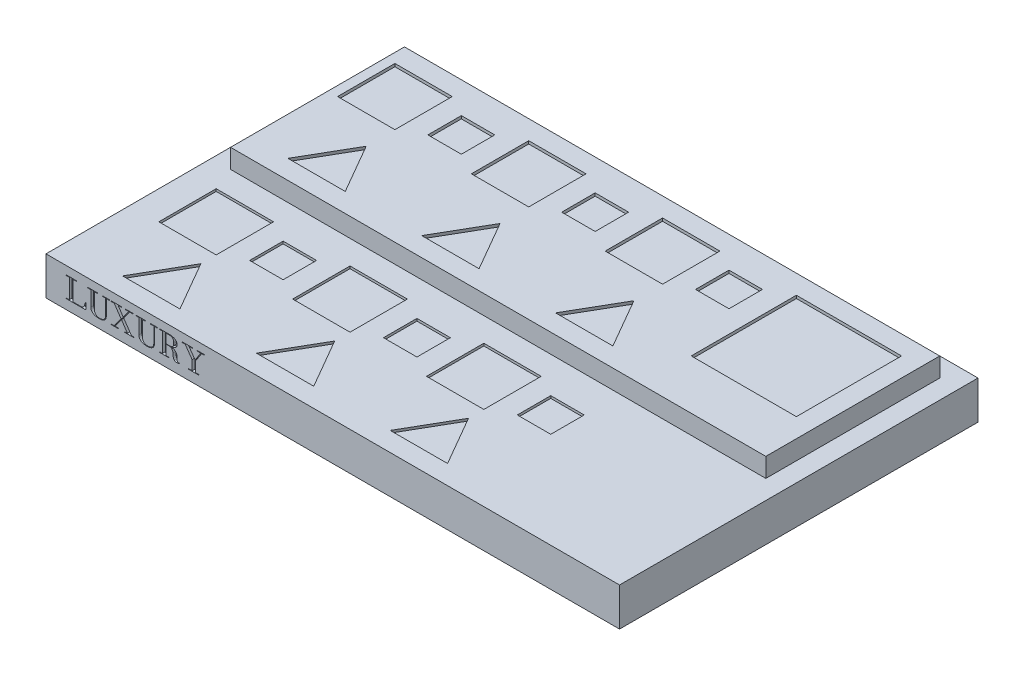
from build123d import *

# Parameters (mm, degrees)
SKETCH1_W           = 600
SKETCH1_H           = 375
BOSS_EXTRUDE3_DEPTH = 40
CUT_EXTRUDE1_DEPTH  = 3
SKETCH5_R           = 25
SKETCH5_W           = 60
SKETCH5_H           = 60
CUT_EXTRUDE2_DEPTH  = 3
SKETCH6_W           = 560
SKETCH6_H           = 181.961524227
BOSS_EXTRUDE4_DEPTH = 20
SKETCH8_W           = 60
SKETCH8_H           = 60
SKETCH8_W_2         = 35
SKETCH8_H_2         = 35
SKETCH8_W_3         = 110
SKETCH8_H_3         = 110
CUT_EXTRUDE12_DEPTH = 3
SKETCH8_7_W         = 60
SKETCH8_7_H         = 60
SKETCH8_7_W_2       = 35
SKETCH8_7_H_2       = 35
CUT_EXTRUDE13_DEPTH = 22.5


with BuildPart() as part:
    # Sketch1 → Boss-Extrude3 (new body)
    with BuildSketch(Plane(origin=(0, 0, 0), x_dir=(1, 0, 0), z_dir=(0, 1, 0))):
        Rectangle(SKETCH1_W, SKETCH1_H)
    extrude(amount=-BOSS_EXTRUDE3_DEPTH)

    # Sketch2 → Cut-Extrude1 (cut)
    with BuildSketch(Plane.XY.offset(187.5)):
        with BuildLine():
            add(Edge.make_bspline(
                [(-258.895558648, -23.936742187), (-258.997269322, -24.328875191), (-259.191725751, -25.078578054), (-259.466634354, -25.9856335), (-259.720538833, -26.645863024), (-259.929426881, -27.099135568), (-260.174917938, -27.515424324), (-260.443382228, -27.901972822), (-260.751834109, -28.246508697), (-261.09308975, -28.555337155), (-261.480890253, -28.810047091), (-261.903130637, -29.031704786), (-262.375316644, -29.200067568), (-262.902279881, -29.313090604), (-263.482805759, -29.39096417), (-263.890288122, -29.397666543), (-264.102662001, -29.401159722)],
                knots=[0, 0, 0, 0, 0.001215404, 0.002323681, 0.002840622, 0.003336647, 0.00381889, 0.004288788, 0.00474608, 0.005203372, 0.005665307, 0.006134016, 0.006631253, 0.007163568, 0.007748504, 0.008385201, 0.008385201, 0.008385201, 0.008385201], degree=3))
            Line((-264.102662001, -29.401159722), (-271.901620931, -29.401159722))
            Line((-271.901620931, -29.401159722), (-271.901620931, -9.040590278))
            Line((-271.901620931, -9.040590278), (-268.289865506, -9.040590278))
            Line((-268.289865506, -9.040590278), (-268.289865506, -8.44175))
            Line((-268.289865506, -8.44175), (-278.85846072, -8.44175))
            Line((-278.85846072, -8.44175), (-278.85846072, -9.040590278))
            Line((-278.85846072, -9.040590278), (-275.588231391, -9.040590278))
            Line((-275.588231391, -9.040590278), (-275.588231391, -29.401159722))
            Line((-275.588231391, -29.401159722), (-278.85846072, -29.401159722))
            Line((-278.85846072, -29.401159722), (-278.85846072, -30))
            Line((-278.85846072, -30), (-259.274512261, -30))
            add(Edge.make_bspline(
                [(-259.274512261, -30), (-259.188418744, -29.996502143), (-259.025444389, -29.989880726), (-258.798907857, -29.938643412), (-258.601632119, -29.855451762), (-258.447477975, -29.724175967), (-258.318622939, -29.566398032), (-258.237314891, -29.368031161), (-258.184675279, -29.138805425), (-258.178414328, -28.974213972), (-258.175078939, -28.886531359)],
                knots=[0, 0, 0, 0, 0.000257994, 0.00048838, 0.000693593, 0.000893072, 0.001089622, 0.00129911, 0.001529496, 0.001792156, 0.001792156, 0.001792156, 0.001792156], degree=3))
            Line((-258.175078939, -28.886531359), (-258.175078939, -24.034989421))
            add(Edge.make_bspline(
                [(-258.175078939, -24.034989421), (-258.177842651, -23.920401065), (-258.182623748, -23.722168357), (-258.229247011, -23.47393322), (-258.325636232, -23.292791061), (-258.432069631, -23.268929615), (-258.479177517, -23.258368435)],
                knots=[0, 0, 0, 0, 0.000342038, 0.000591711, 0.000766887, 0.000905987, 0.000905987, 0.000905987, 0.000905987], degree=3))
            add(Edge.make_bspline(
                [(-258.479177517, -23.258368435), (-258.523973094, -23.26803895), (-258.624594211, -23.28976114), (-258.731891004, -23.446992928), (-258.825800689, -23.660647313), (-258.870391303, -23.837132407), (-258.895558648, -23.936742187)],
                knots=[0, 0, 0, 0, 0.000133151, 0.000299087, 0.000535661, 0.000842197, 0.000842197, 0.000842197, 0.000842197], degree=3))
        make_face()
        with BuildLine():
            Line((-246.179559625, -8.44175), (-256.406628743, -8.44175))
            Line((-256.406628743, -8.44175), (-256.406628743, -9.040590278))
            Line((-256.406628743, -9.040590278), (-253.136399414, -9.040590278))
            Line((-253.136399414, -9.040590278), (-253.136399414, -24.853716363))
            add(Edge.make_bspline(
                [(-253.136399414, -24.853716363), (-253.129091047, -25.127464043), (-253.114938624, -25.657567788), (-252.958944178, -26.414012673), (-252.724115678, -27.107572296), (-252.376163673, -27.72398883), (-251.948943331, -28.269132845), (-251.474815745, -28.768124964), (-250.935649017, -29.203146874), (-250.346164703, -29.587332901), (-249.708489747, -29.911400279), (-249.036208214, -30.189605845), (-248.327052165, -30.414199964), (-247.587754635, -30.583579351), (-246.832406052, -30.707637561), (-246.076557359, -30.794545846), (-245.325933191, -30.854918852), (-244.827605857, -30.861990832), (-244.579533257, -30.865511339)],
                knots=[0, 0, 0, 0, 0.000820063, 0.001588025, 0.002307137, 0.003008747, 0.003699336, 0.004380944, 0.005069248, 0.005772571, 0.006488174, 0.007211897, 0.007953175, 0.008716922, 0.009485284, 0.010248386, 0.010999038, 0.011743146, 0.011743146, 0.011743146, 0.011743146], degree=3))
            add(Edge.make_bspline(
                [(-244.579533257, -30.865511339), (-244.286204943, -30.86127932), (-243.715819197, -30.853050033), (-242.886020591, -30.782033346), (-242.105950809, -30.6661183), (-241.376490544, -30.504556763), (-240.695059396, -30.293231248), (-240.065763069, -30.032630555), (-239.484028494, -29.726540631), (-238.953680878, -29.37655212), (-238.47592973, -28.978014296), (-238.063995768, -28.526866401), (-237.711135186, -28.03053949), (-237.43257444, -27.483314439), (-237.209864747, -26.892060914), (-237.052638716, -26.25466638), (-236.957991457, -25.569230774), (-236.945888478, -25.097308668), (-236.939641276, -24.853716363)],
                knots=[0, 0, 0, 0, 0.000879858, 0.00171091, 0.002496289, 0.003244269, 0.003950093, 0.004633866, 0.005284724, 0.005919235, 0.006536825, 0.0071461, 0.007747075, 0.008358073, 0.00898285, 0.0096387, 0.010323497, 0.011054068, 0.011054068, 0.011054068, 0.011054068], degree=3))
            Line((-236.939641276, -24.853716363), (-236.939641276, -9.040590278))
            Line((-236.939641276, -9.040590278), (-233.669411947, -9.040590278))
            Line((-233.669411947, -9.040590278), (-233.669411947, -8.44175))
            Line((-233.669411947, -8.44175), (-240.818067763, -8.44175))
            Line((-240.818067763, -8.44175), (-240.818067763, -9.040590278))
            Line((-240.818067763, -9.040590278), (-237.547838433, -9.040590278))
            Line((-237.547838433, -9.040590278), (-237.547838433, -24.853716363))
            add(Edge.make_bspline(
                [(-237.547838433, -24.853716363), (-237.55260588, -25.063025506), (-237.56193744, -25.472716696), (-237.653384597, -26.070468151), (-237.801594332, -26.636272823), (-238.014995859, -27.16422664), (-238.27113127, -27.65795862), (-238.576931246, -28.110490803), (-238.931676118, -28.5202205), (-239.32793145, -28.889910044), (-239.768686468, -29.212852709), (-240.240601997, -29.501694813), (-240.754972662, -29.736694882), (-241.29617451, -29.940588118), (-241.867478876, -30.091376299), (-242.459533566, -30.205850096), (-243.074733858, -30.271087827), (-243.492428818, -30.280567881), (-243.704665039, -30.28538482)],
                knots=[0, 0, 0, 0, 0.000627539, 0.001228313, 0.001809345, 0.002378386, 0.002932934, 0.003475331, 0.00401272, 0.004555621, 0.005097391, 0.005649408, 0.006212417, 0.006791202, 0.007382484, 0.007982565, 0.008598931, 0.009235629, 0.009235629, 0.009235629, 0.009235629], degree=3))
            add(Edge.make_bspline(
                [(-243.704665039, -30.28538482), (-243.921616383, -30.280836566), (-244.344064065, -30.271980206), (-244.958637606, -30.204998245), (-245.538599215, -30.099886928), (-246.082722005, -29.943542197), (-246.595668615, -29.749739912), (-247.070561413, -29.503060407), (-247.512306409, -29.218153132), (-247.916569085, -28.889763553), (-248.279205688, -28.518937858), (-248.592645576, -28.106706744), (-248.857207567, -27.654967942), (-249.076874757, -27.169476723), (-249.247685368, -26.64403873), (-249.359289103, -26.079986375), (-249.439112527, -25.479764546), (-249.4461672, -25.066090108), (-249.449788954, -24.853716363)],
                knots=[0, 0, 0, 0, 0.000650724, 0.001267089, 0.001852511, 0.002416744, 0.002963241, 0.003494712, 0.004018969, 0.004537749, 0.005053863, 0.005571312, 0.006087236, 0.006621173, 0.007167109, 0.007740576, 0.008344077, 0.008980774, 0.008980774, 0.008980774, 0.008980774], degree=3))
            Line((-249.449788954, -24.853716363), (-249.449788954, -9.040590278))
            Line((-249.449788954, -9.040590278), (-246.179559625, -9.040590278))
            Line((-246.179559625, -9.040590278), (-246.179559625, -8.44175))
        make_face()
        Polygon((-221.014232639, -9.040590278), (-221.014232639, -8.44175), (-231.92435395, -8.44175), (-231.92435395, -9.040590278), (-228.65412462, -9.040590278), (-221.43061377, -19.665326769), (-228.696230577, -29.401159722), (-232.003887424, -29.401159722), (-232.003887424, -30), (-224.055218424, -30), (-224.055218424, -29.401159722), (-227.858789876, -29.401159722), (-221.014232639, -20.123813856), (-214.815300076, -29.401159722), (-217.893713379, -29.401159722), (-217.893713379, -30), (-207.704071777, -30), (-207.704071777, -29.401159722), (-210.632775011, -29.401159722), (-218.73115408, -17.471138563), (-212.494794, -9.040590278), (-209.070176161, -9.040590278), (-209.070176161, -8.44175), (-217.056272678, -8.44175), (-217.056272678, -9.040590278), (-213.369662218, -9.040590278), (-219.147535211, -16.993937717), (-224.471599555, -9.040590278), align=None)
        with BuildLine():
            Line((-195.876976291, -8.44175), (-206.10404541, -8.44175))
            Line((-206.10404541, -8.44175), (-206.10404541, -9.040590278))
            Line((-206.10404541, -9.040590278), (-202.833816081, -9.040590278))
            Line((-202.833816081, -9.040590278), (-202.833816081, -24.853716363))
            add(Edge.make_bspline(
                [(-202.833816081, -24.853716363), (-202.826507713, -25.127464043), (-202.812355291, -25.657567788), (-202.656360845, -26.414012673), (-202.421532345, -27.107572296), (-202.07358034, -27.72398883), (-201.646359998, -28.269132845), (-201.172232411, -28.768124964), (-200.633065683, -29.203146874), (-200.04358137, -29.587332901), (-199.405906413, -29.911400279), (-198.733624881, -30.189605845), (-198.024468832, -30.414199964), (-197.285171302, -30.583579351), (-196.529822719, -30.707637561), (-195.773974025, -30.794545846), (-195.023349857, -30.854918852), (-194.525022524, -30.861990832), (-194.276949924, -30.865511339)],
                knots=[0, 0, 0, 0, 0.000820063, 0.001588025, 0.002307137, 0.003008747, 0.003699336, 0.004380944, 0.005069248, 0.005772571, 0.006488174, 0.007211897, 0.007953175, 0.008716922, 0.009485284, 0.010248386, 0.010999038, 0.011743146, 0.011743146, 0.011743146, 0.011743146], degree=3))
            add(Edge.make_bspline(
                [(-194.276949924, -30.865511339), (-193.98362161, -30.86127932), (-193.413235863, -30.853050033), (-192.583437257, -30.782033346), (-191.803367475, -30.6661183), (-191.073907211, -30.504556763), (-190.392476063, -30.293231248), (-189.763179736, -30.032630555), (-189.181445161, -29.726540631), (-188.651097544, -29.37655212), (-188.173346397, -28.978014296), (-187.761412434, -28.526866401), (-187.408551853, -28.03053949), (-187.129991106, -27.483314439), (-186.907281413, -26.892060914), (-186.750055383, -26.25466638), (-186.655408124, -25.569230774), (-186.643305144, -25.097308668), (-186.637057943, -24.853716363)],
                knots=[0, 0, 0, 0, 0.000879858, 0.00171091, 0.002496289, 0.003244269, 0.003950093, 0.004633866, 0.005284724, 0.005919235, 0.006536825, 0.0071461, 0.007747075, 0.008358073, 0.00898285, 0.0096387, 0.010323497, 0.011054068, 0.011054068, 0.011054068, 0.011054068], degree=3))
            Line((-186.637057943, -24.853716363), (-186.637057943, -9.040590278))
            Line((-186.637057943, -9.040590278), (-183.366828613, -9.040590278))
            Line((-183.366828613, -9.040590278), (-183.366828613, -8.44175))
            Line((-183.366828613, -8.44175), (-190.515484429, -8.44175))
            Line((-190.515484429, -8.44175), (-190.515484429, -9.040590278))
            Line((-190.515484429, -9.040590278), (-187.2452551, -9.040590278))
            Line((-187.2452551, -9.040590278), (-187.2452551, -24.853716363))
            add(Edge.make_bspline(
                [(-187.2452551, -24.853716363), (-187.250022546, -25.063025506), (-187.259354106, -25.472716696), (-187.350801264, -26.070468151), (-187.499010999, -26.636272823), (-187.712412526, -27.16422664), (-187.968547937, -27.65795862), (-188.274347913, -28.110490803), (-188.629092785, -28.5202205), (-189.025348116, -28.889910044), (-189.466103135, -29.212852709), (-189.938018664, -29.501694813), (-190.452389329, -29.736694882), (-190.993591176, -29.940588118), (-191.564895543, -30.091376299), (-192.156950232, -30.205850096), (-192.772150525, -30.271087827), (-193.189845485, -30.280567881), (-193.402081706, -30.28538482)],
                knots=[0, 0, 0, 0, 0.000627539, 0.001228313, 0.001809345, 0.002378386, 0.002932934, 0.003475331, 0.00401272, 0.004555621, 0.005097391, 0.005649408, 0.006212417, 0.006791202, 0.007382484, 0.007982565, 0.008598931, 0.009235629, 0.009235629, 0.009235629, 0.009235629], degree=3))
            add(Edge.make_bspline(
                [(-193.402081706, -30.28538482), (-193.61903305, -30.280836566), (-194.041480732, -30.271980206), (-194.656054273, -30.204998245), (-195.236015881, -30.099886928), (-195.780138672, -29.943542197), (-196.293085282, -29.749739912), (-196.76797808, -29.503060407), (-197.209723076, -29.218153132), (-197.613985751, -28.889763553), (-197.976622355, -28.518937858), (-198.290062242, -28.106706744), (-198.554624234, -27.654967942), (-198.774291424, -27.169476723), (-198.945102035, -26.64403873), (-199.05670577, -26.079986375), (-199.136529194, -25.479764546), (-199.143583866, -25.066090108), (-199.147205621, -24.853716363)],
                knots=[0, 0, 0, 0, 0.000650724, 0.001267089, 0.001852511, 0.002416744, 0.002963241, 0.003494712, 0.004018969, 0.004537749, 0.005053863, 0.005571312, 0.006087236, 0.006621173, 0.007167109, 0.007740576, 0.008344077, 0.008980774, 0.008980774, 0.008980774, 0.008980774], degree=3))
            Line((-199.147205621, -24.853716363), (-199.147205621, -9.040590278))
            Line((-199.147205621, -9.040590278), (-195.876976291, -9.040590278))
            Line((-195.876976291, -9.040590278), (-195.876976291, -8.44175))
        make_face()
        with BuildLine():
            add(Edge.make_bspline(
                [(-162.608591797, -28.601146539), (-162.646287126, -28.472422793), (-162.732284525, -28.178754908), (-162.787105054, -27.674183296), (-162.833778123, -27.087711291), (-162.858245031, -26.442940738), (-162.875665445, -25.767547008), (-162.891488385, -25.078061812), (-162.92191675, -24.395074879), (-162.994310596, -23.948766735), (-163.029651367, -23.730890842)],
                knots=[0, 0, 0, 0, 0.00040172, 0.000916476, 0.001517141, 0.002168049, 0.002851358, 0.00354402, 0.004237708, 0.004899339, 0.004899339, 0.004899339, 0.004899339], degree=3))
            add(Edge.make_bspline(
                [(-163.029651367, -23.730890842), (-163.071838114, -23.525894791), (-163.153115994, -23.130945055), (-163.319915401, -22.570007176), (-163.530595792, -22.066781915), (-163.779995461, -21.61702983), (-164.067251218, -21.219330003), (-164.365972671, -20.847039837), (-164.714546004, -20.532284404), (-165.080013048, -20.243215636), (-165.475070443, -19.989625271), (-165.901276138, -19.770448222), (-166.352858679, -19.571491447), (-167.009519404, -19.358235974), (-167.877814558, -19.107239815), (-168.592997663, -18.941467548), (-168.961912869, -18.855956706)],
                knots=[0, 0, 0, 0, 0.000627713, 0.001209366, 0.001752428, 0.002261368, 0.002748128, 0.003223145, 0.003689889, 0.004153149, 0.004620337, 0.005095354, 0.005589877, 0.006098817, 0.007164947, 0.008300806, 0.008300806, 0.008300806, 0.008300806], degree=3))
            add(Edge.make_bspline(
                [(-168.961912869, -18.855956706), (-168.721239889, -18.816501543), (-168.251656276, -18.7395195), (-167.574740787, -18.582953894), (-166.937217996, -18.407808927), (-166.346298002, -18.196206421), (-165.793261406, -17.964650672), (-165.28880502, -17.695691796), (-164.822074433, -17.406641087), (-164.400643584, -17.088794004), (-164.024786139, -16.745932282), (-163.693111047, -16.3830527), (-163.423724493, -15.988306373), (-163.187774301, -15.582609018), (-163.017679031, -15.147327775), (-162.888686502, -14.695170146), (-162.812299024, -14.219099708), (-162.804420186, -13.893964558), (-162.800407823, -13.728386827)],
                knots=[0, 0, 0, 0, 0.000731469, 0.00142719, 0.002083323, 0.002713681, 0.003308947, 0.003880272, 0.004426769, 0.004954501, 0.005461178, 0.0059515, 0.006425225, 0.006892367, 0.007356288, 0.007822843, 0.008301258, 0.008797724, 0.008797724, 0.008797724, 0.008797724], degree=3))
            add(Edge.make_bspline(
                [(-162.800407823, -13.728386827), (-162.806864711, -13.525037342), (-162.81954395, -13.125724726), (-162.941855369, -12.542938407), (-163.136543824, -11.99145394), (-163.418572625, -11.478820434), (-163.762071676, -11.003718631), (-164.15420527, -10.55765809), (-164.614756043, -10.16651284), (-165.122029321, -9.809164787), (-165.679959948, -9.491846364), (-166.288402769, -9.213206548), (-166.949250472, -8.983324347), (-167.653779462, -8.786693099), (-168.393618358, -8.63553583), (-169.158629672, -8.521556011), (-169.946358735, -8.45614372), (-170.479170114, -8.446589758), (-170.749076823, -8.44175)],
                knots=[0, 0, 0, 0, 0.000609348, 0.001196562, 0.001778139, 0.002358001, 0.002944824, 0.003534604, 0.004134923, 0.004752761, 0.00539398, 0.006057626, 0.006757534, 0.007490796, 0.008250521, 0.009021328, 0.00981003, 0.010619739, 0.010619739, 0.010619739, 0.010619739], degree=3))
            Line((-170.749076823, -8.44175), (-181.472060547, -8.44175))
            Line((-181.472060547, -8.44175), (-181.472060547, -9.040590278))
            Line((-181.472060547, -9.040590278), (-178.201831217, -9.040590278))
            Line((-178.201831217, -9.040590278), (-178.201831217, -29.382445964))
            Line((-178.201831217, -29.382445964), (-181.472060547, -29.382445964))
            Line((-181.472060547, -29.382445964), (-181.472060547, -29.901752767))
            Line((-181.472060547, -29.901752767), (-171.240312988, -29.901752767))
            Line((-171.240312988, -29.901752767), (-171.240312988, -29.382445964))
            Line((-171.240312988, -29.382445964), (-174.510542318, -29.382445964))
            Line((-174.510542318, -29.382445964), (-174.510542318, -18.986953016))
            Line((-174.510542318, -18.986953016), (-171.35727398, -18.986953016))
            add(Edge.make_bspline(
                [(-171.35727398, -18.986953016), (-171.147789375, -18.995708804), (-170.712547762, -19.013900515), (-170.167873756, -19.123911303), (-169.725507064, -19.261882953), (-169.396141913, -19.407034129), (-169.080895519, -19.59621262), (-168.780036034, -19.827477301), (-168.494770166, -20.100213156), (-168.222076386, -20.415906566), (-167.985373403, -20.789925869), (-167.750619434, -21.203094978), (-167.545616646, -21.672771288), (-167.371874854, -22.203554467), (-167.233603161, -22.795619273), (-167.170224512, -23.214176257), (-167.137321398, -23.431470703)],
                knots=[0, 0, 0, 0, 0.000628323, 0.001305454, 0.001659071, 0.002017239, 0.002382307, 0.002759408, 0.003153204, 0.003564747, 0.004007224, 0.004478448, 0.004989577, 0.005541415, 0.006151929, 0.006811074, 0.006811074, 0.006811074, 0.006811074], degree=3))
            add(Edge.make_bspline(
                [(-167.137321398, -23.431470703), (-167.101781509, -23.710257191), (-167.030285677, -24.271093835), (-167.002317601, -25.117367414), (-166.971368964, -25.952703642), (-166.903125776, -26.759244277), (-166.768416006, -27.519684842), (-166.601966486, -28.116529827), (-166.415228314, -28.55684911), (-166.23520137, -28.858215152), (-166.019671213, -29.136398848), (-165.851233507, -29.300121756), (-165.766538574, -29.382445964)],
                knots=[0, 0, 0, 0, 0.000842652, 0.001695168, 0.002538119, 0.003350943, 0.004120898, 0.004852233, 0.005204237, 0.005552458, 0.005902467, 0.006256455, 0.006256455, 0.006256455, 0.006256455], degree=3))
            add(Edge.make_bspline(
                [(-165.766538574, -29.382445964), (-165.682978792, -29.455695094), (-165.517143172, -29.601067839), (-165.228965477, -29.764795464), (-164.930692126, -29.911946603), (-164.491305406, -30.037091976), (-163.905632392, -30.133800427), (-163.426206716, -30.150479353), (-163.179361437, -30.159066949)],
                knots=[0, 0, 0, 0, 0.000332466, 0.000659823, 0.000990506, 0.001327938, 0.002025543, 0.002765935, 0.002765935, 0.002765935, 0.002765935], degree=3))
            add(Edge.make_bspline(
                [(-163.179361437, -30.159066949), (-162.963877467, -30.153699934), (-162.531289326, -30.142925549), (-161.891953916, -30.055030394), (-161.278684141, -29.926715058), (-160.705120976, -29.787458089), (-160.196665054, -29.620316994), (-159.763722928, -29.446887989), (-159.411390127, -29.288777088), (-159.22912638, -29.15118924), (-159.151224881, -29.092382704)],
                knots=[0, 0, 0, 0, 0.000646235, 0.001297328, 0.001932253, 0.002525696, 0.003067184, 0.003535449, 0.003926707, 0.004218763, 0.004218763, 0.004218763, 0.004218763], degree=3))
            add(Edge.make_bspline(
                [(-159.151224881, -29.092382704), (-159.116719516, -29.062382752), (-159.056772653, -29.010263233), (-159.040970385, -28.933250812), (-159.034263889, -28.900566678)],
                knots=[0, 0, 0, 0, 0.000132492, 0.00023018, 0.00023018, 0.00023018, 0.00023018], degree=3))
            add(Edge.make_bspline(
                [(-159.034263889, -28.900566678), (-159.039803083, -28.871388958), (-159.051710948, -28.808664247), (-159.116548097, -28.804530365), (-159.151224881, -28.802319444)],
                knots=[0, 0, 0, 0, 7.9945e-05, 0.000171862, 0.000171862, 0.000171862, 0.000171862], degree=3))
            add(Edge.make_bspline(
                [(-159.151224881, -28.802319444), (-159.182768813, -28.807390723), (-159.262851349, -28.820265492), (-159.336082497, -28.855698361), (-159.380468424, -28.877174479)],
                knots=[0, 0, 0, 0, 9.5422e-05, 0.000242253, 0.000242253, 0.000242253, 0.000242253], degree=3))
            add(Edge.make_bspline(
                [(-159.380468424, -28.877174479), (-159.509226076, -28.957856728), (-159.763375303, -29.117111973), (-160.18434677, -29.281365188), (-160.627823491, -29.38318652), (-160.933148952, -29.395109113), (-161.088098904, -29.401159722)],
                knots=[0, 0, 0, 0, 0.000454965, 0.000898035, 0.00134865, 0.001812971, 0.001812971, 0.001812971, 0.001812971], degree=3))
            add(Edge.make_bspline(
                [(-161.088098904, -29.401159722), (-161.181817477, -29.398356267), (-161.362240458, -29.392959176), (-161.619353957, -29.355210823), (-161.852147087, -29.297192965), (-162.055883736, -29.205664741), (-162.235968578, -29.094482456), (-162.389244372, -28.954828939), (-162.517706261, -28.790863884), (-162.578077473, -28.664843105), (-162.608591797, -28.601146539)],
                knots=[0, 0, 0, 0, 0.000281057, 0.000541079, 0.000778253, 0.00099819, 0.001208459, 0.001410501, 0.001617307, 0.001828667, 0.001828667, 0.001828667, 0.001828667], degree=3))
        make_face()
        with BuildLine():
            Line((-174.510542318, -18.645426921), (-174.510542318, -9.040590278))
            Line((-174.510542318, -9.040590278), (-170.749076823, -9.040590278))
            add(Edge.make_bspline(
                [(-170.749076823, -9.040590278), (-170.574334649, -9.044871153), (-170.235135262, -9.05318094), (-169.741903363, -9.097551814), (-169.281864842, -9.182075638), (-168.856557751, -9.299049005), (-168.462339856, -9.442249619), (-168.105707411, -9.626895586), (-167.780087262, -9.840799033), (-167.492581281, -10.094094166), (-167.231498623, -10.374051398), (-167.012758626, -10.694195005), (-166.830233287, -11.045886389), (-166.672979677, -11.424987066), (-166.559836141, -11.842282602), (-166.467673937, -12.288527298), (-166.425011118, -12.771619443), (-166.416546537, -13.102984504), (-166.412163249, -13.274578179)],
                knots=[0, 0, 0, 0, 0.000524319, 0.001017778, 0.001483935, 0.001925447, 0.002339958, 0.002739602, 0.003127574, 0.003505631, 0.003886428, 0.004273157, 0.0046645, 0.005073696, 0.00550169, 0.005959532, 0.006439021, 0.00695399, 0.00695399, 0.00695399, 0.00695399], degree=3))
            Line((-166.412163249, -13.274578179), (-166.412163249, -14.439509657))
            add(Edge.make_bspline(
                [(-166.412163249, -14.439509657), (-166.416609914, -14.609539183), (-166.425234817, -14.939334197), (-166.467284457, -15.419392665), (-166.559695094, -15.862543094), (-166.673818002, -16.276390709), (-166.830330224, -16.654082358), (-167.011570423, -17.005091932), (-167.231572147, -17.321599512), (-167.494009972, -17.596861468), (-167.780132304, -17.849604089), (-168.104321144, -18.065164826), (-168.464841119, -18.241063827), (-168.854433063, -18.394849604), (-169.282955077, -18.501741343), (-169.741702745, -18.589125573), (-170.235190354, -18.632654962), (-170.57435338, -18.641084404), (-170.749076823, -18.645426921)],
                knots=[0, 0, 0, 0, 0.000510293, 0.000989782, 0.001443036, 0.001866531, 0.002275728, 0.00266707, 0.00304996, 0.003427322, 0.003805379, 0.004193351, 0.004590881, 0.005007052, 0.005447347, 0.005913504, 0.006406963, 0.006931282, 0.006931282, 0.006931282, 0.006931282], degree=3))
            Line((-170.749076823, -18.645426921), (-174.510542318, -18.645426921))
        make_face(mode=Mode.SUBTRACT)
        Polygon((-146.907748264, -8.44175), (-157.518449436, -8.44175), (-157.518449436, -9.040590278), (-154.47746365, -9.040590278), (-147.09956429, -19.412691026), (-147.09956429, -29.401159722), (-150.748747233, -29.401159722), (-150.748747233, -30), (-139.759092448, -30), (-139.759092448, -29.401159722), (-143.408275391, -29.401159722), (-143.408275391, -18.584607205), (-137.134487793, -9.040590278), (-134.05607449, -9.040590278), (-134.05607449, -8.44175), (-141.812927463, -8.44175), (-141.812927463, -9.040590278), (-138.126317003, -9.040590278), (-144.016472548, -18.158869195), (-150.407221137, -9.040590278), (-146.907748264, -9.040590278), align=None)
    extrude(amount=-CUT_EXTRUDE1_DEPTH, mode=Mode.SUBTRACT)

    # Sketch5 → Cut-Extrude2 (cut)
    with BuildSketch(Plane(origin=(0, 0, 0), x_dir=(1, 0, 0), z_dir=(0, 1, 0))):
        with Locations((-175, 130)):
            Circle(SKETCH5_R)
        with Locations((-240, 117.5)):
            Rectangle(SKETCH5_W, SKETCH5_H)
        Polygon((-210, 57.5), (-240, 5.538475773), (-180, 5.538475773), align=None)
    extrude(amount=-CUT_EXTRUDE2_DEPTH, mode=Mode.SUBTRACT)

    # Sketch6 → Boss-Extrude4 (add)
    with BuildSketch(Plane(origin=(0, 0, 0), x_dir=(1, 0, 0), z_dir=(0, 1, 0))):
        with Locations((0, 76.519237886)):
            Rectangle(SKETCH6_W, SKETCH6_H)
    extrude(amount=BOSS_EXTRUDE4_DEPTH)

    # Sketch8 → Cut-Extrude12 (cut)
    with BuildSketch(Plane(origin=(0, 20, 0), x_dir=(1, 0, 0), z_dir=(0, 1, 0))):
        with Locations((-240, 117.5)):
            Rectangle(SKETCH8_W, SKETCH8_H)
        with Locations((-170.5, 117.5)):
            Rectangle(SKETCH8_W_2, SKETCH8_H_2)
        Polygon((100, 5.538475773), (70, 57.5), (40, 5.538475773), align=None)
        with Locations((205, 92.5)):
            Rectangle(SKETCH8_W_3, SKETCH8_H_3)
        with Locations((109.5, 117.5)):
            Rectangle(SKETCH8_W_2, SKETCH8_H_2)
        with Locations((40, 117.5)):
            Rectangle(SKETCH8_W, SKETCH8_H)
        with Locations((-30.5, 117.5)):
            Rectangle(SKETCH8_W_2, SKETCH8_H_2)
        Polygon((-210, 57.5), (-240, 5.538475773), (-180, 5.538475773), align=None)
        Polygon((-70, 57.5), (-100, 5.538475773), (-40, 5.538475773), align=None)
        with Locations((-100, 117.5)):
            Rectangle(SKETCH8_W, SKETCH8_H)
    extrude(amount=-CUT_EXTRUDE12_DEPTH, mode=Mode.SUBTRACT)

    # Sketch8_7 → Cut-Extrude13 (cut)
    with BuildSketch(Plane(origin=(0, 20, 0), x_dir=(1, 0, 0), z_dir=(0, 1, 0))):
        with Locations((-240, -69.461524227)):
            Rectangle(SKETCH8_7_W, SKETCH8_7_H)
        with Locations((-170, -69.461524227)):
            Rectangle(SKETCH8_7_W_2, SKETCH8_7_H_2)
        with Locations((-100, -69.461524227)):
            Rectangle(SKETCH8_7_W, SKETCH8_7_H)
        with Locations((-30, -69.461524227)):
            Rectangle(SKETCH8_7_W_2, SKETCH8_7_H_2)
        with Locations((40, -69.461524227)):
            Rectangle(SKETCH8_7_W, SKETCH8_7_H)
        with Locations((110, -69.461524227)):
            Rectangle(SKETCH8_7_W_2, SKETCH8_7_H_2)
        Polygon((100, -167.397400375), (69.955576224, -115.461524227), (40, -167.448696533), align=None)
        Polygon((-40, -167.397400375), (-70.044423776, -115.461524227), (-100, -167.448696533), align=None)
        Polygon((-180, -167.397400375), (-210.044423776, -115.461524227), (-240, -167.448696533), align=None)
    extrude(amount=-CUT_EXTRUDE13_DEPTH, mode=Mode.SUBTRACT)


solid = part.part
